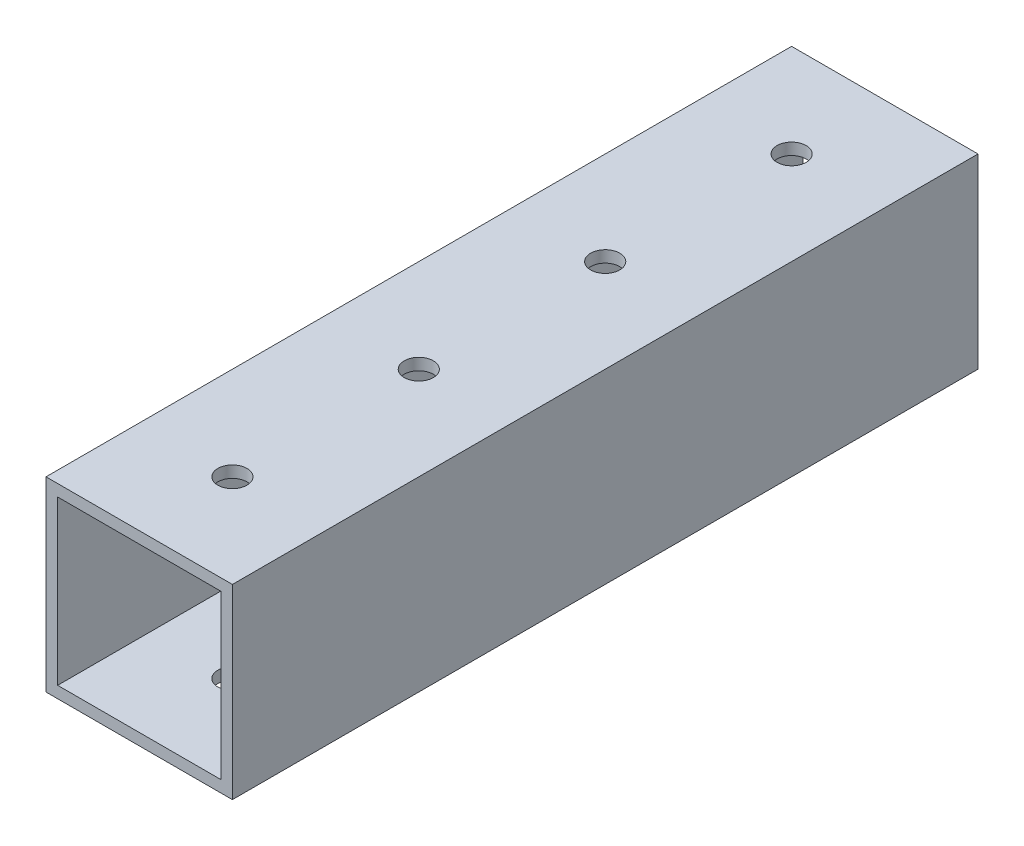
from build123d import *

# Parameters (mm, degrees)
SKETCH1_W           = 25.4
SKETCH1_H           = 25.4
SKETCH1_W_2         = 22.225
SKETCH1_H_2         = 22.225
BOSS_EXTRUDE1_DEPTH = 101.6
SKETCH2_R           = 1.984375
CUT_EXTRUDE1_DEPTH  = 26.4


with BuildPart() as part:
    # Sketch1 → Boss-Extrude1 (new body)
    with BuildSketch(Plane.XY):
        Rectangle(SKETCH1_W, SKETCH1_H)
        Rectangle(SKETCH1_W_2, SKETCH1_H_2, mode=Mode.SUBTRACT)
    extrude(amount=BOSS_EXTRUDE1_DEPTH)

    # Sketch2 → Cut-Extrude1 (cut, through all)
    with BuildSketch(Plane(origin=(0, 12.7, 0), x_dir=(1, 0, 0), z_dir=(0, 1, 0))):
        with Locations((0, -88.9)):
            Circle(SKETCH2_R)
        with Locations((0, -63.5)):
            Circle(SKETCH2_R)
        with Locations((0, -38.1)):
            Circle(SKETCH2_R)
        with Locations((0, -12.7)):
            Circle(SKETCH2_R)
        with Locations((0, 12.7)):
            Circle(SKETCH2_R)
        with Locations((0, 38.1)):
            Circle(SKETCH2_R)
        with Locations((0, 63.5)):
            Circle(SKETCH2_R)
        with Locations((0, 88.9)):
            Circle(SKETCH2_R)
        with Locations((0, 114.3)):
            Circle(SKETCH2_R)
        with Locations((0, 139.7)):
            Circle(SKETCH2_R)
        with Locations((0, 165.1)):
            Circle(SKETCH2_R)
        with Locations((0, 190.5)):
            Circle(SKETCH2_R)
    extrude(amount=-CUT_EXTRUDE1_DEPTH, mode=Mode.SUBTRACT)


solid = part.part
